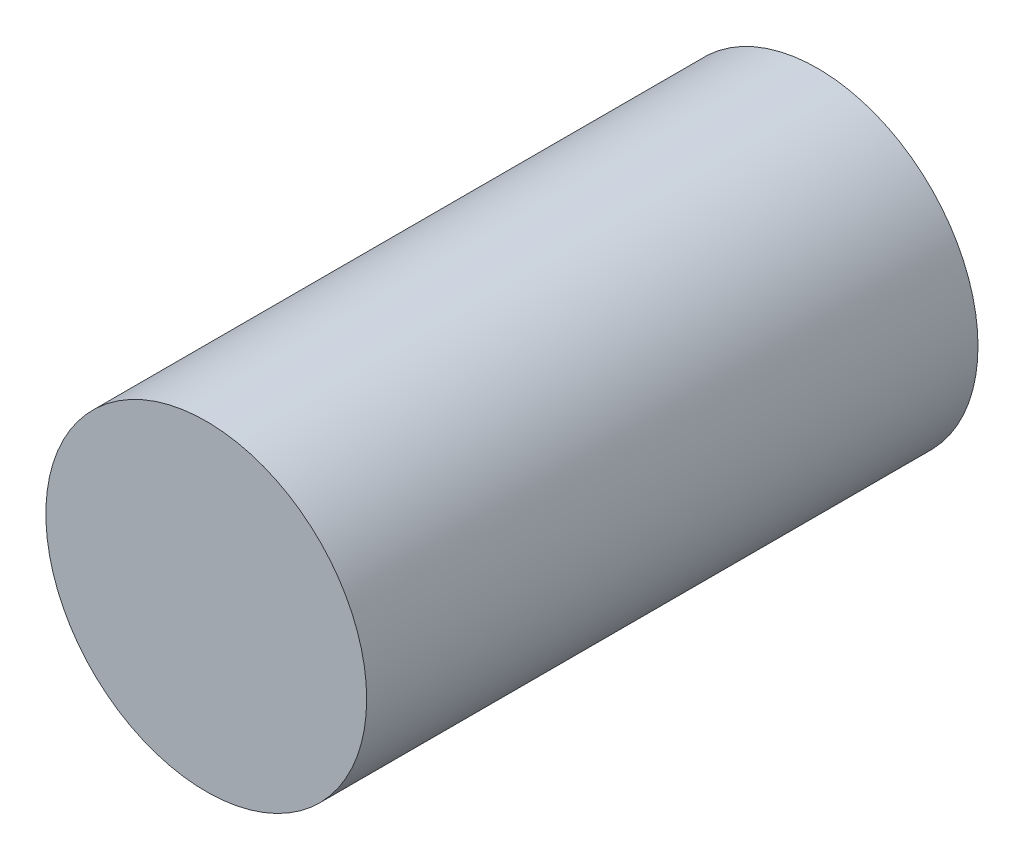
from build123d import *

# Parameters (mm, degrees)
GK_W = 85.75
GK_H = 22.5


with BuildPart() as part:
    # GK → Rotation_GK (revolve)
    with BuildSketch(Plane(origin=(0, 0, 0), x_dir=(0, 0, -1), z_dir=(1, 0, 0)), mode=Mode.PRIVATE) as rotation_gk_sk:
        with Locations((42.875, 11.25)):
            Rectangle(GK_W, GK_H)
    revolve(rotation_gk_sk.sketch.rotate(Axis((0, 0, 0), (0, 0, -1)), 90), axis=Axis((0, 0, 0), (0, 0, -1)))  # turned: the seam where the file's is


solid = part.part
